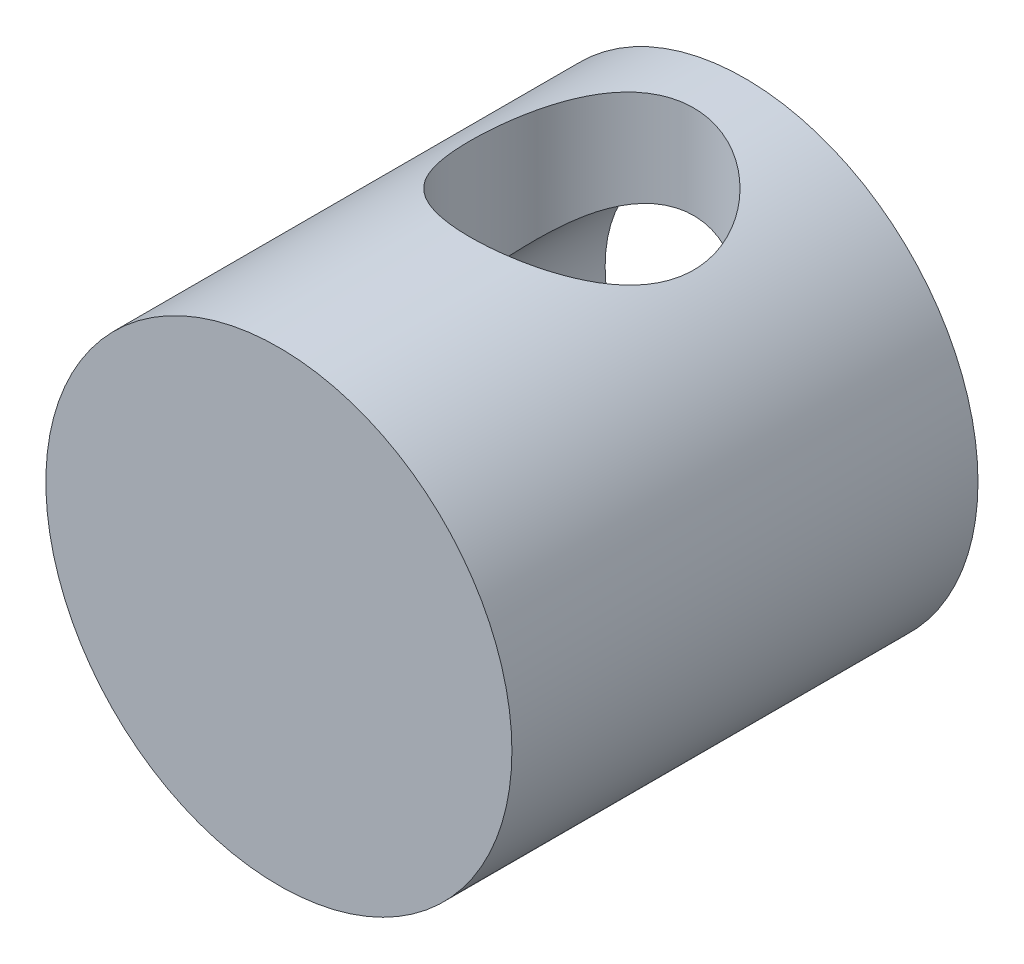
from build123d import *

# Parameters (mm, degrees)
SKETCH1_R           = 25
BOSS_EXTRUDE1_DEPTH = 50
SKETCH2_R           = 15
CUT_EXTRUDE1_DEPTH  = 30
SKETCH3_R           = 12
CUT_EXTRUDE2_DEPTH  = 51


with BuildPart() as part:
    # Sketch1 → Boss-Extrude1 (new body)
    with BuildSketch(Plane.XY):
        Circle(SKETCH1_R)
    extrude(amount=BOSS_EXTRUDE1_DEPTH)

    # Sketch2 → Cut-Extrude1 (cut)
    with BuildSketch(Plane(origin=(0, 0, 0), x_dir=(-1, 0, 0), z_dir=(0, 0, -1))):
        Circle(SKETCH2_R)
    extrude(amount=-CUT_EXTRUDE1_DEPTH, mode=Mode.SUBTRACT)

    # Sketch3 → Cut-Extrude2 (cut, through all)
    with BuildSketch(Plane(origin=(0, 25, 0), x_dir=(1, 0, 0), z_dir=(0, 1, 0))):
        with Locations((0, -17.5)):
            Circle(SKETCH3_R)
    extrude(amount=-CUT_EXTRUDE2_DEPTH, mode=Mode.SUBTRACT)


solid = part.part
